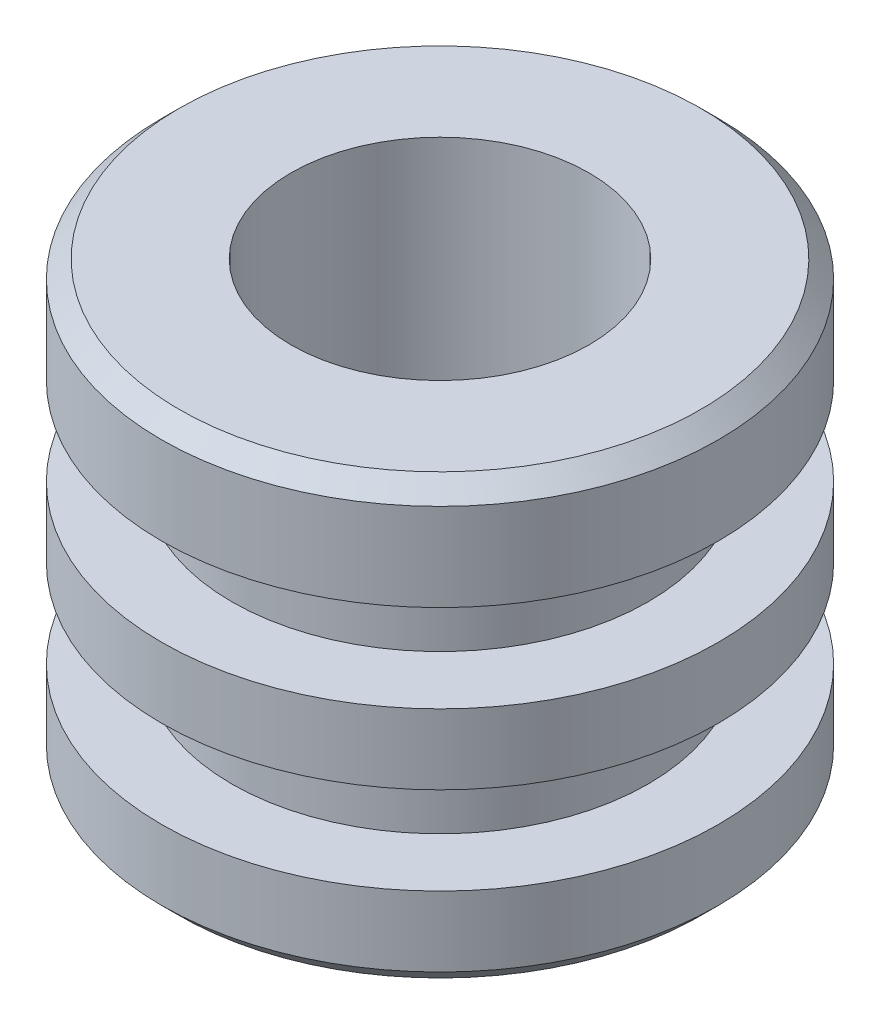
from build123d import *


with BuildPart() as part:
    # Croquis1 → Revolución4 (revolve)
    with BuildSketch(Plane.XY):
        Polygon((6.5, -10), (6.5, -0.5), (8.5, -0.5), (8.5, 15), (14.875, 15), (15.875, 14), (15.875, 9), (11.875, 9), (11.875, 4), (15.875, 4), (15.875, 0), (11.875, 0), (11.875, -5), (15.875, -5), (15.875, -9), (14.875, -10), align=None)
    revolve(axis=Axis((0, 22.686183704, 0), (0, -1, 0)))


solid = part.part
